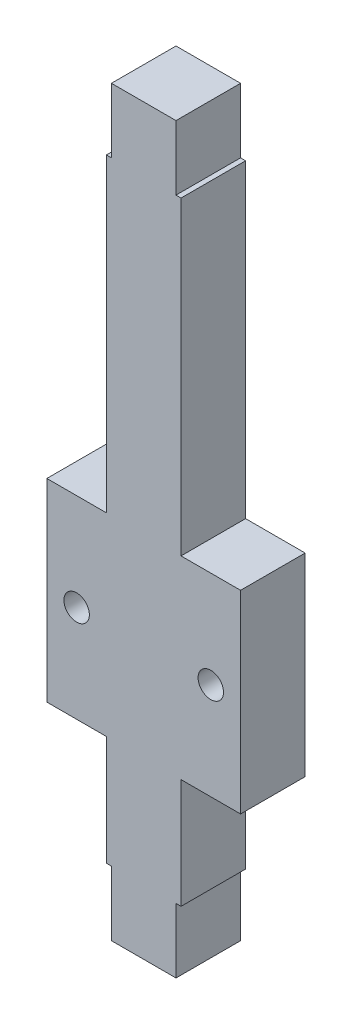
from build123d import *

# Parameters (mm, degrees)
BOSS_EXTRUDE1_DEPTH = 6.35
SKETCH2_R           = 1.25
CUT_EXTRUDE1_DEPTH  = 7.35


with BuildPart() as part:
    # Sketch1 → Boss-Extrude1 (new body)
    with BuildSketch(Plane.XY):
        Polygon((0, -6.35), (6.35, -6.35), (6.35, 0), (6.8453, 0), (6.8453, 10.795), (12.7, 10.795), (12.7, 29.845), (6.8453, 29.845), (6.8453, 60.325), (6.35, 60.325), (6.35, 66.675), (0, 66.675), (0, 60.325), (-0.4953, 60.325), (-0.4953, 29.845), (-6.35, 29.845), (-6.35, 10.795), (-0.4953, 10.795), (-0.4953, 0), (0, 0), align=None)
    extrude(amount=BOSS_EXTRUDE1_DEPTH)

    # Sketch2 → Cut-Extrude1 (cut, through all)
    with BuildSketch(Plane.XY.offset(6.35)):
        with Locations((-3.42265, 20.32)):
            Circle(SKETCH2_R)
        with Locations((9.77265, 20.32)):
            Circle(SKETCH2_R)
    extrude(amount=-CUT_EXTRUDE1_DEPTH, mode=Mode.SUBTRACT)


solid = part.part
